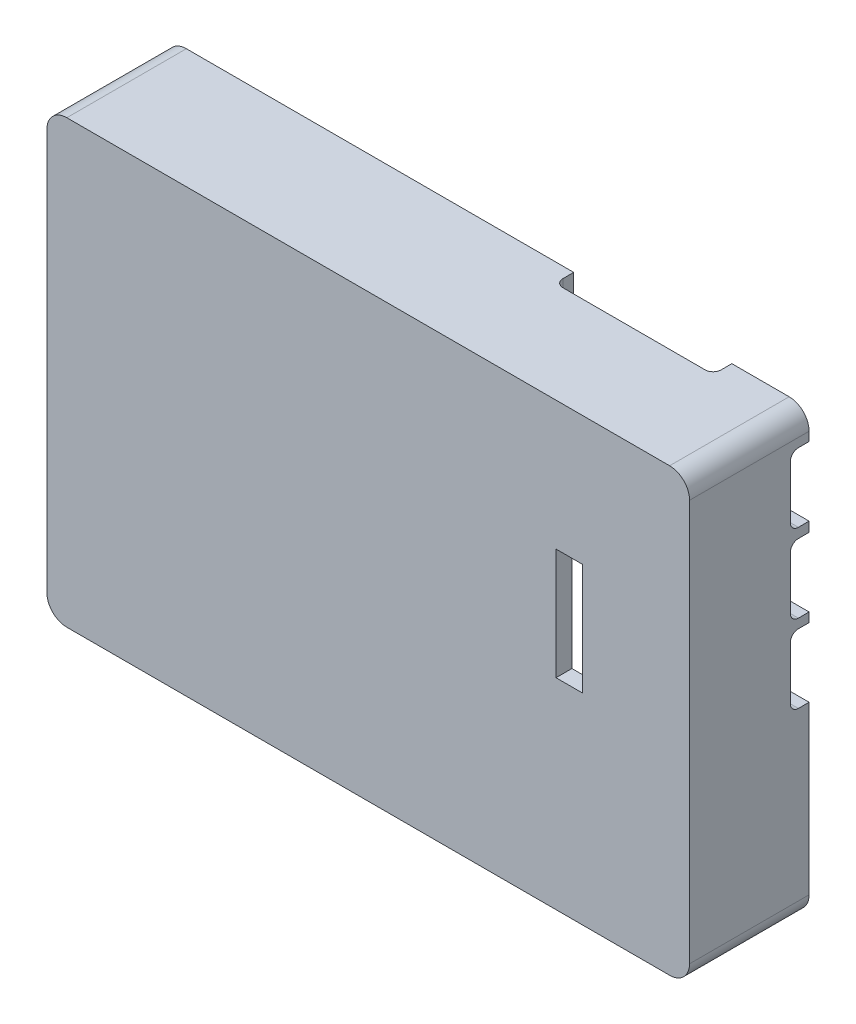
from build123d import *

# Parameters (mm, degrees)
SKETCH_1_R          = 2.5
EXTRUDE_1_DEPTH     = 2.5
EXTRUDE_1_2_DEPTH   = 2.5
EXTRUDE_1_3_DEPTH   = 2.5
SKETCH_2_R          = 1.5
EXTRUDE_2_DEPTH     = 2.5
SKETCH_3_W          = 5.060610533
SKETCH_3_H          = 13.613755096
EXTRUDE_3_DEPTH     = 2.5
SKETCH_4_W          = 80.650749302
SKETCH_4_H          = 55.377698756
EXTRUDE_4_DEPTH     = 2
SKETCH_5_W          = 80.650749302
SKETCH_5_H          = 55.377698756
SKETCH_5_W_2        = 75.650749302
SKETCH_5_H_2        = 50.377698756
EXTRUDE_5_DEPTH     = 13
FILLET_1_R          = 2.5
CUT_EXTRUDE_1_DEPTH = 2.6
SKETCH_8_W          = 3.315326588
SKETCH_8_H          = 13.986534041
CUT_EXTRUDE_2_DEPTH = 2
SKETCH_9_W          = 2.35
SKETCH_9_H          = 8.65
SKETCH_9_H_2        = 8.647957695
CUT_EXTRUDE_3_DEPTH = 3
FILLET_2_R          = 1
SKETCH_10_W         = 19.844488107
SKETCH_10_H         = 2.35
CUT_EXTRUDE_4_DEPTH = 3
FILLET_3_R          = 1
SKETCH_11_R         = 1.25
CUT_EXTRUDE_5_DEPTH = 6.8


with BuildPart() as part:
    # 草图1 → 凸台-拉伸1 (new body)
    with BuildSketch(Plane.XY):
        with Locations((-25.173975108, -5.08001016)):
            Circle(SKETCH_1_R)
    extrude(amount=EXTRUDE_1_DEPTH)



with BuildPart() as body_2:
    # 草图1 → Extrude 1 2 (new body)
    with BuildSketch(Plane.XY):
        with Locations((-25.173975108, -54.483108966)):
            Circle(SKETCH_1_R)
    extrude(amount=EXTRUDE_1_2_DEPTH)


with BuildPart() as body_3:
    # 草图1 → Extrude 1 3 (new body)
    with BuildSketch(Plane.XY):
        with Locations((27.94005588, -46.193418847)):
            Circle(SKETCH_1_R)
    extrude(amount=EXTRUDE_1_3_DEPTH)


with BuildPart() as part_1:
    add(part.part)

    add(body_2.part)  # 凸台-拉伸2 merges body 2

    add(body_3.part)  # 凸台-拉伸2 merges body 3
    # 草图2 → 凸台-拉伸2 (add)
    with BuildSketch(Plane(origin=(0, 0, 0), x_dir=(-1, 0, 0), z_dir=(0, 0, -1))):
        with Locations((25.173975108, -5.08001016)):
            Circle(SKETCH_2_R)
        with Locations((25.173975108, -54.483108966)):
            Circle(SKETCH_2_R)
        with Locations((-27.94005588, -46.193418847)):
            Circle(SKETCH_2_R)
    extrude(amount=EXTRUDE_2_DEPTH)



with BuildPart() as body_2_2:
    # 草图3 → 凸台-拉伸3 (new body)
    with BuildSketch(Plane(origin=(0, 0, 0), x_dir=(-1, 0, 0), z_dir=(0, 0, -1))):
        with Locations((-5.471223868, -19.889889862)):
            Rectangle(SKETCH_3_W, SKETCH_3_H)
    extrude(amount=-EXTRUDE_3_DEPTH)


with BuildPart() as part_2:
    add(part_1.part)

    add(body_2_2.part)  # 凸台-拉伸4 merges body 2 2
    # 草图4 → 凸台-拉伸4 (add)
    with BuildSketch(Plane.XY.offset(2.5)):
        with Locations((-9.398018796, -29.781559563)):
            Rectangle(SKETCH_4_W, SKETCH_4_H)
    extrude(amount=EXTRUDE_4_DEPTH)

    # 草图5 → 凸台-拉伸5 (add)
    with BuildSketch(Plane(origin=(0, 0, 2.5), x_dir=(-1, 0, 0), z_dir=(0, 0, -1))):
        with Locations((9.398018796, -29.781559563)):
            Rectangle(SKETCH_5_W, SKETCH_5_H)
        with Locations((9.398018796, -29.781559563)):
            Rectangle(SKETCH_5_W_2, SKETCH_5_H_2, mode=Mode.SUBTRACT)
    extrude(amount=EXTRUDE_5_DEPTH)

    # 圆角1
    fillet_1_edges = [part_2.edges().sort_by_distance(p)[0] for p in [
        (-49.723393447, -2.092710185, -3),
        (-49.723393447, -57.470408941, -3),
        (30.927355855, -57.470408941, -3),
        (30.927355855, -2.092710185, -3),
    ]]
    fillet(fillet_1_edges, radius=FILLET_1_R)

    # 草图7 → 切除-拉伸1 (cut)
    with BuildSketch(Plane.XZ.offset(57.470408941)):
        with BuildLine():
            Line((-1.675382515, -6.58006372), (-6.175382515, -6.58006372))
            ThreePointArc((-6.175382515, -6.58006372), (-9.675382515, -3.08006372), (-6.175382515, 0.41993628))
            Line((-6.175382515, 0.41993628), (-1.675382515, 0.41993628))
            ThreePointArc((-1.675382515, 0.41993628), (1.824617485, -3.08006372), (-1.675382515, -6.58006372))
        make_face()
    extrude(amount=-CUT_EXTRUDE_1_DEPTH, mode=Mode.SUBTRACT)

    # 草图8 → 切除-拉伸2 (cut)
    with BuildSketch(Plane.XY.offset(4.5)):
        with Locations((15.823203351, -25.268606613)):
            Rectangle(SKETCH_8_W, SKETCH_8_H)
    extrude(amount=-CUT_EXTRUDE_2_DEPTH, mode=Mode.SUBTRACT)

    # 草图9 → 切除-拉伸3 (cut)
    with BuildSketch(Plane(origin=(30.927355855, 0, 0), x_dir=(0, 0, -1), z_dir=(1, 0, 0))):
        with Locations((9.325, -10.033571247)):
            Rectangle(SKETCH_9_W, SKETCH_9_H)
        with Locations((9.325, -19.906568383)):
            Rectangle(SKETCH_9_W, SKETCH_9_H_2)
        with Locations((9.325, -29.718110236)):
            Rectangle(SKETCH_9_W, SKETCH_9_H)
    extrude(amount=-CUT_EXTRUDE_3_DEPTH, mode=Mode.SUBTRACT)

    # 圆角2
    fillet_2_edges = [part_2.edges().sort_by_distance(p)[0] for p in [
        (29.677355855, -14.358571247, -8.15),
        (29.677355855, -5.708571247, -8.15),
        (29.677355855, -24.23054723, -8.15),
        (29.677355855, -15.582589535, -8.15),
        (29.677355855, -34.043110236, -8.15),
        (29.677355855, -25.393110236, -8.15),
    ]]
    fillet(fillet_2_edges, radius=FILLET_2_R)

    # 草图10 → 切除-拉伸4 (cut)
    with BuildSketch(Plane(origin=(0, -2.092710185, 0), x_dir=(1, 0, 0), z_dir=(0, 1, 0))):
        with Locations((11.312306284, 9.325)):
            Rectangle(SKETCH_10_W, SKETCH_10_H)
    extrude(amount=-CUT_EXTRUDE_4_DEPTH, mode=Mode.SUBTRACT)

    # 圆角3
    fillet_3_edges = [part_2.edges().sort_by_distance(p)[0] for p in [
        (21.234550337, -3.342710185, -8.15),
        (1.39006223, -3.342710185, -8.15),
    ]]
    fillet(fillet_3_edges, radius=FILLET_3_R)

    # 草图11 → 切除-拉伸5 (cut)
    with BuildSketch(Plane.XZ.offset(57.470408941)):
        with Locations((-18.53025758, -6.91322852)):
            Circle(SKETCH_11_R)
    extrude(amount=-CUT_EXTRUDE_5_DEPTH, mode=Mode.SUBTRACT)


solid = part_2.part
